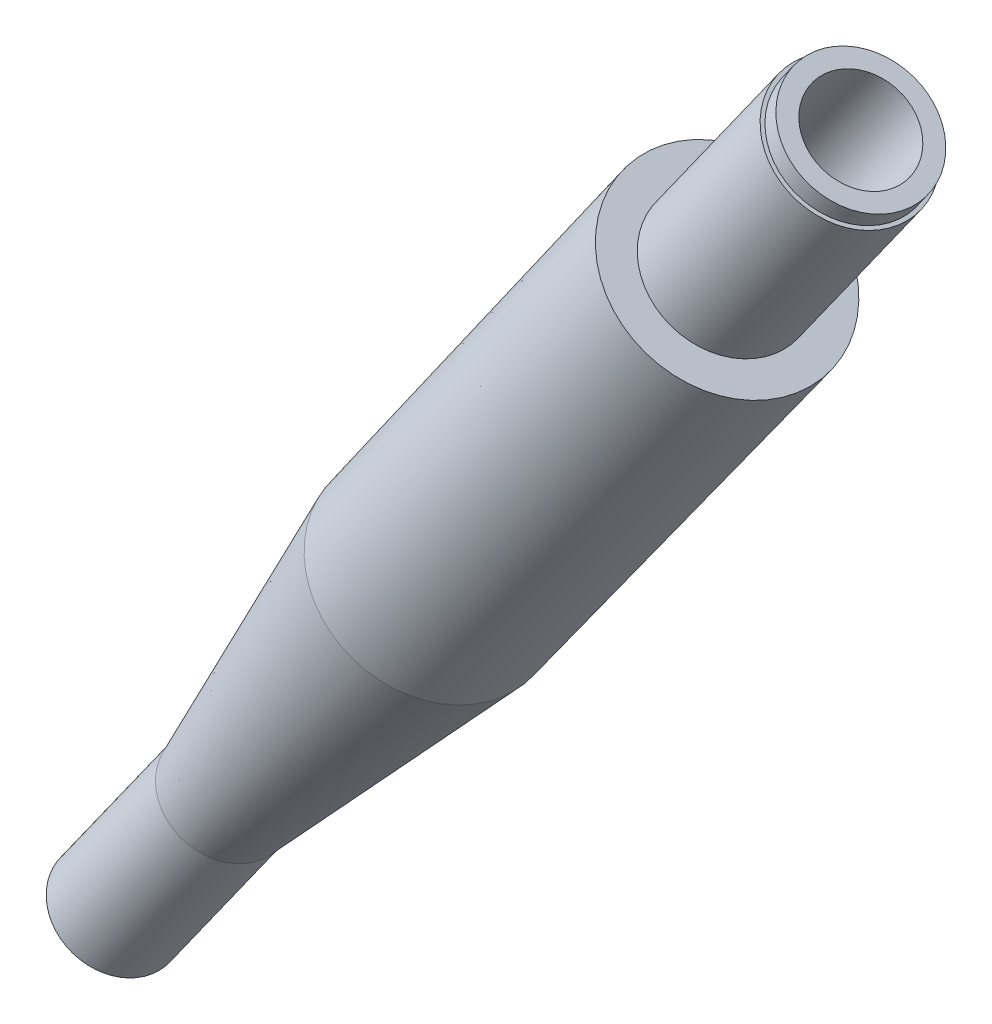
from build123d import *

# Parameters (mm, degrees)
SKETCH2_OUTSIDE_W  = 81.185
SKETCH2_OUTSIDE_H  = 67.044
SKETCH2_OUTSIDE_R  = 3.495
CUT_EXTRUDE1_DEPTH = 1


with BuildPart() as part:
    # Sketch1 → Revolve1 (revolve)
    with BuildSketch(Plane(origin=(96.031948768, 24.259878967, -114.32637478), x_dir=(0.579754018, 0.814791555, 0), z_dir=(0, 0, -1))):
        Polygon((-201.145317806, 47.619722085), (-136.905317806, 47.619722085), (-136.905317806, 47.980853052), (-145.145317806, 47.980853052), (-145.145317806, 50.169722085), (-132.905317806, 50.169722085), (-132.905317806, 51.314722085), (-145.145317806, 51.314722085), (-145.145317806, 53.039722085), (-172.145317806, 52.884722085), (-191.145317806, 50.459722085), (-201.145317806, 50.459722085), align=None)
    revolve(axis=Axis((18.217289915, -167.239352557, -114.32637478), (0.579754018, 0.814791555, 0)))

    # Sketch2 outside → Cut-Extrude1 (cut)
    with BuildSketch(Plane(origin=(-33.314790755, -46.820909057, 0), x_dir=(0.663885278, -0.472378678, -0.579754018), z_dir=(0.579754018, 0.814791555, 0))):
        with Locations((157.4895, 28.254)):
            Rectangle(SKETCH2_OUTSIDE_W, SKETCH2_OUTSIDE_H)
        with Locations((157.375670059, 28.335096914)):
            Circle(SKETCH2_OUTSIDE_R, mode=Mode.SUBTRACT)
    extrude(amount=-CUT_EXTRUDE1_DEPTH, mode=Mode.SUBTRACT)


solid = part.part
